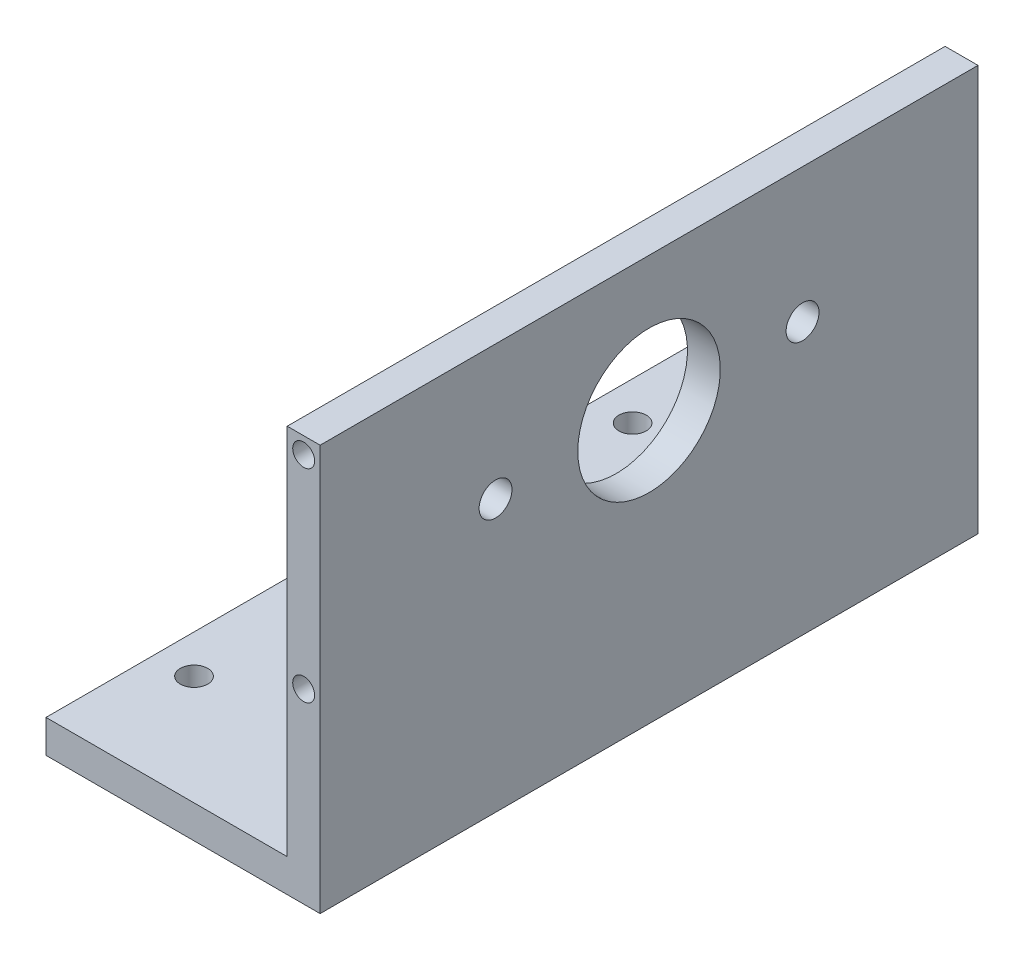
from build123d import *

# Parameters (mm, degrees)
SKETCH_1_W          = 44
SKETCH_1_H          = 120
EXTRUDE_1_DEPTH     = 6
SKETCH_1_3_W        = 6
SKETCH_1_3_H        = 120
EXTRUDE_2_DEPTH     = 74
SKETCH_2_R          = 13
SKETCH_2_R_2        = 3
CUT_EXTRUDE_1_DEPTH = 105.938076979
SKETCH_3_R          = 2.5
CUT_EXTRUDE_2_DEPTH = 10
SKETCH_4_R          = 2
CUT_EXTRUDE_3_DEPTH = 20


with BuildPart() as part:
    # 草图1 → 凸台-拉伸1 (new body)
    with BuildSketch(Plane(origin=(0, 0, 0), x_dir=(1, 0, 0), z_dir=(0, 1, 0))):
        with Locations((-3, 0)):
            Rectangle(SKETCH_1_W, SKETCH_1_H)
    extrude(amount=EXTRUDE_1_DEPTH)

    # 草图1<3> → 凸台-拉伸2 (add)
    with BuildSketch(Plane(origin=(0, 0, 0), x_dir=(1, 0, 0), z_dir=(0, 1, 0))):
        with Locations((22, 0)):
            Rectangle(SKETCH_1_3_W, SKETCH_1_3_H)
    extrude(amount=EXTRUDE_2_DEPTH)

    # 草图2 → 切除-拉伸1 (cut, through all)
    with BuildSketch(Plane.ZY.offset(-19)):
        with Locations((0, 49.5)):
            Circle(SKETCH_2_R)
        with Locations((-28, 49.5)):
            Circle(SKETCH_2_R_2)
        with Locations((28, 49.5)):
            Circle(SKETCH_2_R_2)
    extrude(amount=-CUT_EXTRUDE_1_DEPTH, mode=Mode.SUBTRACT)

    # 草图3 → 切除-拉伸2 (cut)
    with BuildSketch(Plane(origin=(0, 6, 0), x_dir=(1, 0, 0), z_dir=(0, 1, 0))):
        with Locations((-18, 40)):
            Circle(SKETCH_3_R)
        with Locations((12, 40)):
            Circle(SKETCH_3_R)
        with Locations((-18, -40)):
            Circle(SKETCH_3_R)
        with Locations((12, -40)):
            Circle(SKETCH_3_R)
    extrude(amount=-CUT_EXTRUDE_2_DEPTH, mode=Mode.SUBTRACT)

    # 草图4 → 切除-拉伸3 (cut)
    with BuildSketch(Plane(origin=(0, 0, -60), x_dir=(-1, 0, 0), z_dir=(0, 0, -1))):
        with Locations((-22, 34)):
            Circle(SKETCH_4_R)
        with Locations((-22, 71)):
            Circle(SKETCH_4_R)
    cut_extrude_3 = extrude(amount=-CUT_EXTRUDE_3_DEPTH, mode=Mode.SUBTRACT)

    # 镜向1: 切除-拉伸3 across plane
    add(cut_extrude_3.mirror(Plane(origin=(0, 0, 0), x_dir=(1, 0, 0), z_dir=(0, 0, -1))), mode=Mode.SUBTRACT)


solid = part.part
